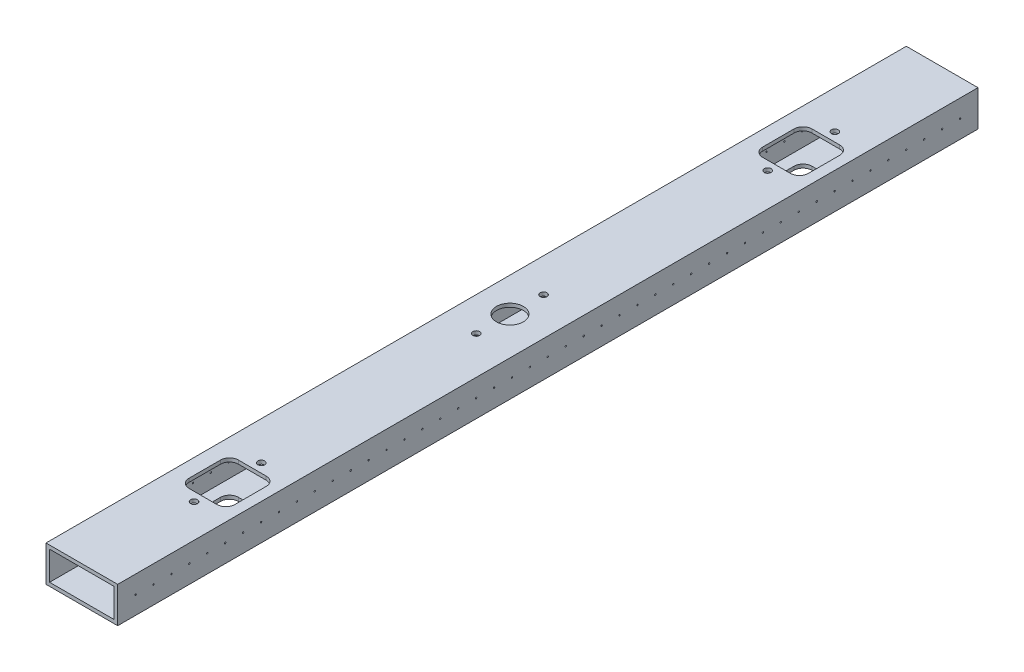
from build123d import *

# Parameters (mm, degrees)
SKETCH1_W           = 50.8
SKETCH1_H           = 25.4
SKETCH1_W_2         = 45.72
SKETCH1_H_2         = 20.32
BOSS_EXTRUDE1_DEPTH = 609.6
SKETCH2_R           = 2.413
CUT_EXTRUDE1_DEPTH  = 26.4
SKETCH2_9_R         = 2.413
SKETCH2_9_R_2       = 9.525
CUT_EXTRUDE2_DEPTH  = 26.4
SKETCH5_R           = 0.5
CUT_EXTRUDE5_DEPTH  = 143.002


with BuildPart() as part:
    # Sketch1 → Boss-Extrude1 (new body)
    with BuildSketch(Plane.XY):
        with Locations((25.4, -12.7)):
            Rectangle(SKETCH1_W, SKETCH1_H)
        with Locations((25.4, -12.7)):
            Rectangle(SKETCH1_W_2, SKETCH1_H_2, mode=Mode.SUBTRACT)
    extrude(amount=BOSS_EXTRUDE1_DEPTH)

    # Sketch2 → Cut-Extrude1 (cut, through all)
    with BuildSketch(Plane(origin=(0, 0, 0), x_dir=(1, 0, 0), z_dir=(0, 1, 0))):
        with Locations((27.124, -77.7875)):
            Circle(SKETCH2_R)
        with Locations((27.124, -125.4125)):
            Circle(SKETCH2_R)
        with BuildLine():
            Line((17.284613044, -84.1375), (36.963386956, -84.1375))
            ThreePointArc((36.963386956, -84.1375), (41.453515016, -85.997371939), (43.313386956, -90.4875))
            Line((43.313386956, -90.4875), (43.313386956, -112.7125))
            ThreePointArc((43.313386956, -112.7125), (41.453515016, -117.202628061), (36.963386956, -119.0625))
            Line((36.963386956, -119.0625), (17.284613044, -119.0625))
            ThreePointArc((17.284613044, -119.0625), (12.794484984, -117.202628061), (10.934613044, -112.7125))
            Line((10.934613044, -112.7125), (10.934613044, -90.4875))
            ThreePointArc((10.934613044, -90.4875), (12.794484984, -85.997371939), (17.284613044, -84.1375))
        make_face()
    extrude(amount=-CUT_EXTRUDE1_DEPTH, mode=Mode.SUBTRACT)

    # Sketch2_9 → Cut-Extrude2 (cut, through all)
    with BuildSketch(Plane(origin=(0, 0, 0), x_dir=(1, 0, 0), z_dir=(0, 1, 0))):
        with Locations((27.124, -531.8125)):
            Circle(SKETCH2_9_R)
        with Locations((27.124, -484.1875)):
            Circle(SKETCH2_9_R)
        with Locations((23.949, -304.8)):
            Circle(SKETCH2_9_R_2)
        with Locations((23.949, -280.9875)):
            Circle(SKETCH2_9_R)
        with Locations((23.949, -328.6125)):
            Circle(SKETCH2_9_R)
        with BuildLine():
            Line((10.934613044, -496.8875), (10.934613044, -519.1125))
            ThreePointArc((10.934613044, -519.1125), (12.794484984, -523.602628061), (17.284613044, -525.4625))
            Line((17.284613044, -525.4625), (36.963386956, -525.4625))
            ThreePointArc((36.963386956, -525.4625), (41.453515016, -523.602628061), (43.313386956, -519.1125))
            Line((43.313386956, -519.1125), (43.313386956, -496.8875))
            ThreePointArc((43.313386956, -496.8875), (41.453515016, -492.397371939), (36.963386956, -490.5375))
            Line((36.963386956, -490.5375), (17.284613044, -490.5375))
            ThreePointArc((17.284613044, -490.5375), (12.794484984, -492.397371939), (10.934613044, -496.8875))
        make_face()
    extrude(amount=-CUT_EXTRUDE2_DEPTH, mode=Mode.SUBTRACT)

    # Sketch5 → Cut-Extrude5 (cut)
    with BuildSketch(Plane(origin=(50.8, 0, 0), x_dir=(0, 0, -1), z_dir=(1, 0, 0))):
        with Locations((-12.7, -12.7)):
            Circle(SKETCH5_R)
        with Locations((-25.4, -12.7)):
            Circle(SKETCH5_R)
        with Locations((-38.1, -12.7)):
            Circle(SKETCH5_R)
        with Locations((-50.8, -12.7)):
            Circle(SKETCH5_R)
        with Locations((-63.5, -12.7)):
            Circle(SKETCH5_R)
        with Locations((-76.2, -12.7)):
            Circle(SKETCH5_R)
        with Locations((-88.9, -12.7)):
            Circle(SKETCH5_R)
        with Locations((-101.6, -12.7)):
            Circle(SKETCH5_R)
        with Locations((-114.3, -12.7)):
            Circle(SKETCH5_R)
        with Locations((-127, -12.7)):
            Circle(SKETCH5_R)
        with Locations((-139.7, -12.7)):
            Circle(SKETCH5_R)
        with Locations((-152.4, -12.7)):
            Circle(SKETCH5_R)
        with Locations((-165.1, -12.7)):
            Circle(SKETCH5_R)
        with Locations((-177.8, -12.7)):
            Circle(SKETCH5_R)
        with Locations((-190.5, -12.7)):
            Circle(SKETCH5_R)
        with Locations((-203.2, -12.7)):
            Circle(SKETCH5_R)
        with Locations((-215.9, -12.7)):
            Circle(SKETCH5_R)
        with Locations((-228.6, -12.7)):
            Circle(SKETCH5_R)
        with Locations((-241.3, -12.7)):
            Circle(SKETCH5_R)
        with Locations((-254, -12.7)):
            Circle(SKETCH5_R)
        with Locations((-266.7, -12.7)):
            Circle(SKETCH5_R)
        with Locations((-279.4, -12.7)):
            Circle(SKETCH5_R)
        with Locations((-292.1, -12.7)):
            Circle(SKETCH5_R)
        with Locations((-304.8, -12.7)):
            Circle(SKETCH5_R)
        with Locations((-317.5, -12.7)):
            Circle(SKETCH5_R)
        with Locations((-330.2, -12.7)):
            Circle(SKETCH5_R)
        with Locations((-342.9, -12.7)):
            Circle(SKETCH5_R)
        with Locations((-355.6, -12.7)):
            Circle(SKETCH5_R)
        with Locations((-368.3, -12.7)):
            Circle(SKETCH5_R)
        with Locations((-381, -12.7)):
            Circle(SKETCH5_R)
        with Locations((-393.7, -12.7)):
            Circle(SKETCH5_R)
        with Locations((-406.4, -12.7)):
            Circle(SKETCH5_R)
        with Locations((-419.1, -12.7)):
            Circle(SKETCH5_R)
        with Locations((-431.8, -12.7)):
            Circle(SKETCH5_R)
        with Locations((-444.5, -12.7)):
            Circle(SKETCH5_R)
        with Locations((-457.2, -12.7)):
            Circle(SKETCH5_R)
        with Locations((-469.9, -12.7)):
            Circle(SKETCH5_R)
        with Locations((-482.6, -12.7)):
            Circle(SKETCH5_R)
        with Locations((-495.3, -12.7)):
            Circle(SKETCH5_R)
        with Locations((-508, -12.7)):
            Circle(SKETCH5_R)
        with Locations((-520.7, -12.7)):
            Circle(SKETCH5_R)
        with Locations((-533.4, -12.7)):
            Circle(SKETCH5_R)
        with Locations((-546.1, -12.7)):
            Circle(SKETCH5_R)
        with Locations((-558.8, -12.7)):
            Circle(SKETCH5_R)
        with Locations((-571.5, -12.7)):
            Circle(SKETCH5_R)
        with Locations((-584.2, -12.7)):
            Circle(SKETCH5_R)
        with Locations((-596.9, -12.7)):
            Circle(SKETCH5_R)
    extrude(amount=-CUT_EXTRUDE5_DEPTH, mode=Mode.SUBTRACT)


solid = part.part
